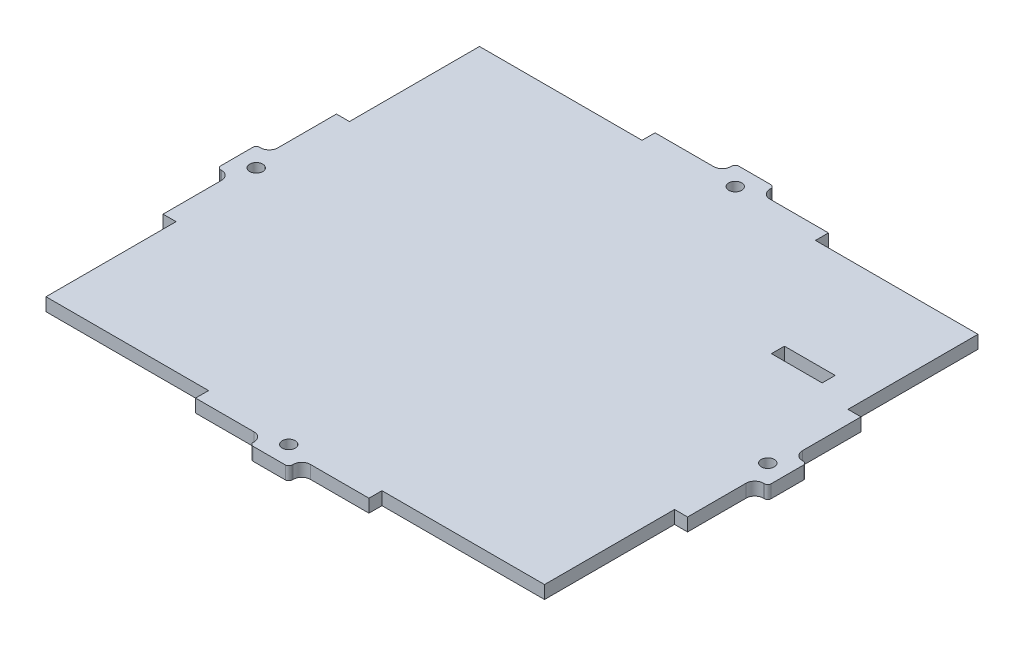
from build123d import *

# Parameters (mm, degrees)
ESBO_O1_W                = 115
ESBO_O1_H                = 100
RESSALTO_EXTRUS_O1_DEPTH = 1.5
RESSALTO_EXTRUS_O2_DEPTH = 3
ESBO_O2_R                = 1.5
CORTE_EXTRUS_O1_DEPTH    = 4
SKETCH2_W                = 11.7
SKETCH2_H                = 3
CUT_EXTRUDE3_DEPTH       = 2.5
CUT_EXTRUDE3_DEPTH_BACK  = 2.5


with BuildPart() as part:
    # Esboço1 → Ressalto-extrusão1 (new body, symmetric)
    with BuildSketch(Plane(origin=(0, 0, 0), x_dir=(1, 0, 0), z_dir=(0, 1, 0))):
        Rectangle(ESBO_O1_W, ESBO_O1_H)
    extrude(amount=RESSALTO_EXTRUS_O1_DEPTH, both=True)

    # Esboço4 → Ressalto-extrusão2 (add, through all)
    with BuildSketch(Plane(origin=(0, 1.5, 0), x_dir=(1, 0, 0), z_dir=(0, 1, 0))):
        with BuildLine():
            Line((6.5, 53), (20, 53))
            Line((20, 53), (20, 50))
            Line((20, 50), (-20, 50))
            Line((-20, 50), (-20, 53))
            Line((-20, 53), (-6.5, 53))
            ThreePointArc((-6.5, 53), (-5.085786438, 53.585786438), (-4.5, 55))
            Line((-4.5, 55), (-4.5, 55.2))
            ThreePointArc((-4.5, 55.2), (-4.265685425, 55.765685425), (-3.7, 56))
            Line((-3.7, 56), (3.7, 56))
            ThreePointArc((3.7, 56), (4.265685425, 55.765685425), (4.5, 55.2))
            Line((4.5, 55.2), (4.5, 55))
            ThreePointArc((4.5, 55), (5.085786438, 53.585786438), (6.5, 53))
        make_face()
        with BuildLine():
            Line((-63.5, 3.7), (-63.5, -3.7))
            ThreePointArc((-63.5, -3.7), (-63.265685425, -4.265685425), (-62.7, -4.5))
            Line((-62.7, -4.5), (-62.5, -4.5))
            ThreePointArc((-62.5, -4.5), (-61.085786438, -5.085786438), (-60.5, -6.5))
            Line((-60.5, -6.5), (-60.5, -20))
            Line((-60.5, -20), (-57.5, -20))
            Line((-57.5, -20), (-57.5, 20))
            Line((-57.5, 20), (-60.5, 20))
            Line((-60.5, 20), (-60.5, 6.5))
            ThreePointArc((-60.5, 6.5), (-61.085786438, 5.085786438), (-62.5, 4.5))
            Line((-62.5, 4.5), (-62.7, 4.5))
            ThreePointArc((-62.7, 4.5), (-63.265685425, 4.265685425), (-63.5, 3.7))
        make_face()
        with BuildLine():
            Line((4.5, -55.2), (4.5, -55))
            ThreePointArc((4.5, -55), (5.085786438, -53.585786438), (6.5, -53))
            Line((6.5, -53), (20, -53))
            Line((20, -53), (20, -50))
            Line((20, -50), (-20, -50))
            Line((-20, -50), (-20, -53))
            Line((-20, -53), (-6.5, -53))
            ThreePointArc((-6.5, -53), (-5.085786438, -53.585786438), (-4.5, -55))
            Line((-4.5, -55), (-4.5, -55.2))
            ThreePointArc((-4.5, -55.2), (-4.265685425, -55.765685425), (-3.7, -56))
            Line((-3.7, -56), (3.7, -56))
            ThreePointArc((3.7, -56), (4.265685425, -55.765685425), (4.5, -55.2))
        make_face()
        with BuildLine():
            Line((57.5, 20), (60.5, 20))
            Line((60.5, 20), (60.5, 6.5))
            ThreePointArc((60.5, 6.5), (61.085786438, 5.085786438), (62.5, 4.5))
            Line((62.5, 4.5), (62.7, 4.5))
            ThreePointArc((62.7, 4.5), (63.265685425, 4.265685425), (63.5, 3.7))
            Line((63.5, 3.7), (63.5, -3.7))
            ThreePointArc((63.5, -3.7), (63.265685425, -4.265685425), (62.7, -4.5))
            Line((62.7, -4.5), (62.5, -4.5))
            ThreePointArc((62.5, -4.5), (61.085786438, -5.085786438), (60.5, -6.5))
            Line((60.5, -6.5), (60.5, -20))
            Line((60.5, -20), (57.5, -20))
            Line((57.5, -20), (57.5, 20))
        make_face()
    extrude(amount=-RESSALTO_EXTRUS_O2_DEPTH)

    # Esboço2 → Corte-extrusão1 (cut, through all)
    with BuildSketch(Plane(origin=(0, 1.5, 0), x_dir=(1, 0, 0), z_dir=(0, 1, 0))):
        with Locations((0, -51.5)):
            Circle(ESBO_O2_R)
        with Locations((0, 51.5)):
            Circle(ESBO_O2_R)
        with Locations((59, 0)):
            Circle(ESBO_O2_R)
        with Locations((-59, 0)):
            Circle(ESBO_O2_R)
    extrude(amount=-CORTE_EXTRUS_O1_DEPTH, mode=Mode.SUBTRACT)

    # Sketch2 → Cut-Extrude3 (cut, two sides)
    with BuildSketch(Plane(origin=(0, 0, 0), x_dir=(1, 0, 0), z_dir=(0, 1, 0))) as cut_extrude3_sk:
        with Locations((43.4, 23.8)):
            Rectangle(SKETCH2_W, SKETCH2_H)
    extrude(amount=CUT_EXTRUDE3_DEPTH, mode=Mode.SUBTRACT)
    extrude(cut_extrude3_sk.sketch, amount=-CUT_EXTRUDE3_DEPTH_BACK, mode=Mode.SUBTRACT)


solid = part.part
